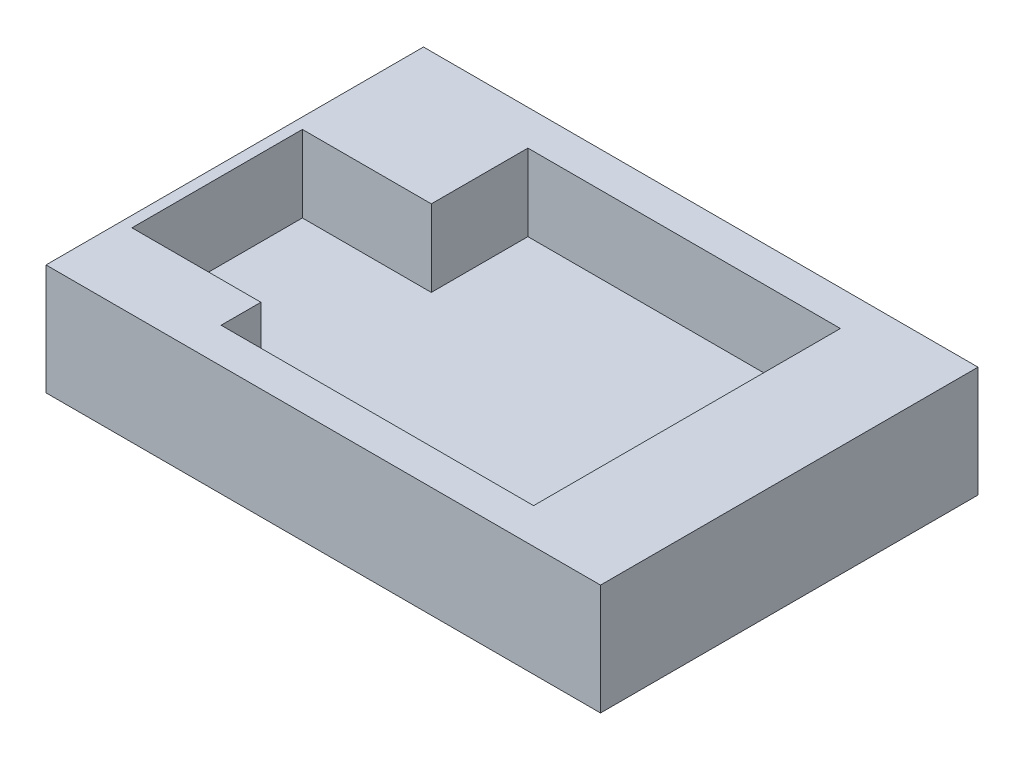
from build123d import *

# Parameters (mm, degrees)
SKETCH1_W           = 97.6
SKETCH1_H           = 66.43745389
BOSS_EXTRUDE1_DEPTH = 6
SKETCH4_W           = 24.6
SKETCH4_H           = 54
SKETCH4_H_2         = 6.218726945
SKETCH4_W_2         = 55
SKETCH4_W_3         = 18
BOSS_EXTRUDE2_DEPTH = 13.5
SKETCH5_W           = 34.693830492
SKETCH5_H           = 30
CUT_EXTRUDE1_DEPTH  = 13.5


with BuildPart() as part:
    # Sketch1 → Boss-Extrude1 (new body)
    with BuildSketch(Plane(origin=(0, 0, 0), x_dir=(1, 0, 0), z_dir=(0, 1, 0))):
        Rectangle(SKETCH1_W, SKETCH1_H)
    extrude(amount=BOSS_EXTRUDE1_DEPTH)

    # Sketch4 → Boss-Extrude2 (add)
    with BuildSketch(Plane(origin=(0, 6, 0), x_dir=(1, 0, 0), z_dir=(0, 1, 0))):
        with Locations((-36.5, 0)):
            Rectangle(SKETCH4_W, SKETCH4_H)
        with Locations((-36.5, -30.109363473)):
            Rectangle(SKETCH4_W, SKETCH4_H_2)
        with Locations((3.3, -30.109363473)):
            Rectangle(SKETCH4_W_2, SKETCH4_H_2)
        with Locations((39.8, -30.109363473)):
            Rectangle(SKETCH4_W_3, SKETCH4_H_2)
        with Locations((39.8, 0)):
            Rectangle(SKETCH4_W_3, SKETCH4_H)
        with Locations((39.8, 30.109363473)):
            Rectangle(SKETCH4_W_3, SKETCH4_H_2)
        with Locations((-36.5, 30.109363473)):
            Rectangle(SKETCH4_W, SKETCH4_H_2)
        with Locations((3.3, 30.109363473)):
            Rectangle(SKETCH4_W_2, SKETCH4_H_2)
    extrude(amount=BOSS_EXTRUDE2_DEPTH)

    # Sketch5 → Cut-Extrude1 (cut)
    with BuildSketch(Plane(origin=(0, 19.5, 0), x_dir=(1, 0, 0), z_dir=(0, 1, 0))):
        with Locations((-29.546650011, -5)):
            Rectangle(SKETCH5_W, SKETCH5_H)
    extrude(amount=-CUT_EXTRUDE1_DEPTH, mode=Mode.SUBTRACT)


solid = part.part
